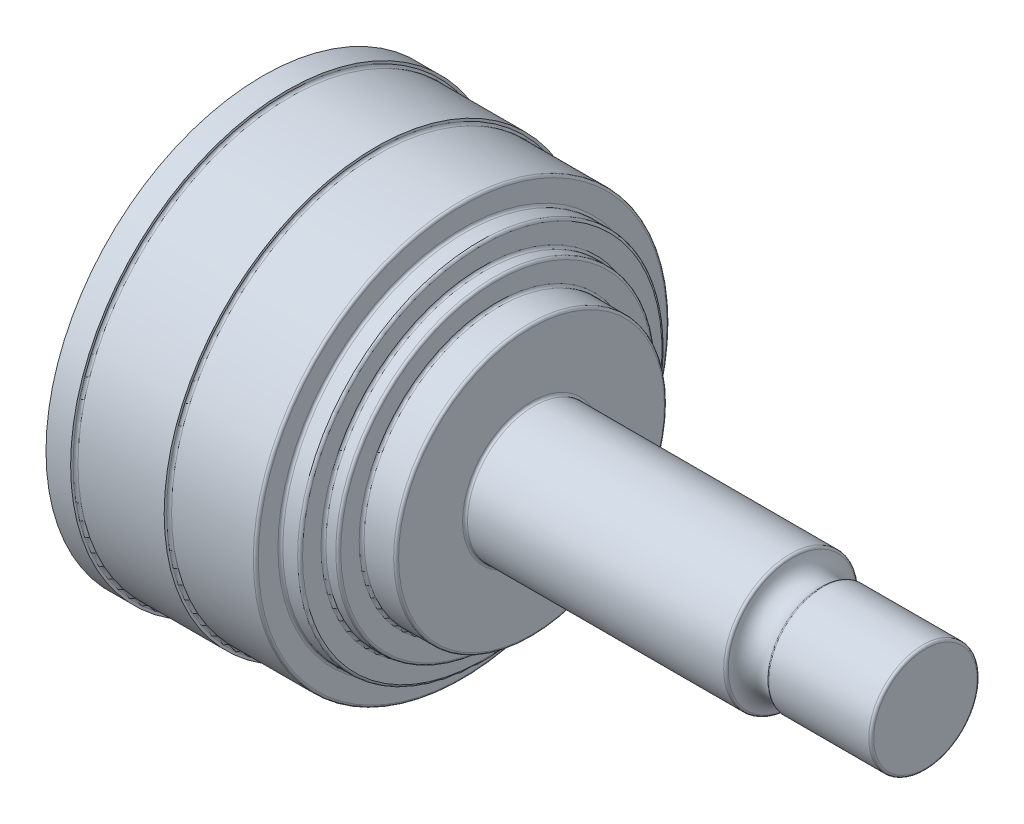
from build123d import *

# Parameters (mm, degrees)
FILLET1_R = 0.5


with BuildPart() as part:
    # Sketch1 → Revolve1 (revolve)
    with BuildSketch(Plane.XY):
        with BuildLine():
            Line((134.6, 0), (134.6, 11))
            Line((134.6, 11), (113.6, 11))
            ThreePointArc((113.6, 11), (109.766666667, 10.25), (107.6, 13.5))
            Line((107.6, 13.5), (54.6, 13.5))
            Line((54.6, 13.5), (54.6, 27.5))
            Line((54.6, 27.5), (47.6, 27.5))
            Line((47.6, 27.5), (47.6, 32.25))
            Line((47.6, 32.25), (44.6, 32.25))
            Line((44.6, 32.25), (44.6, 37))
            Line((44.6, 37), (40.6, 37))
            Line((40.6, 37), (40.6, 42))
            Line((40.6, 42), (23, 42))
            Line((23, 42), (23, 43))
            Line((23, 43), (5, 43))
            Line((5, 43), (5, 44))
            Line((5, 44), (0, 44))
            Line((0, 44), (0, 0))
            Line((0, 0), (134.6, 0))
        make_face()
    revolve(axis=Axis((-159.727345132, 0, 0), (1, 0, 0)))

    # Fillet1
    fillet1_edges = [part.edges().sort_by_distance(p)[0] for p in [
        (5, -43, 0),
        (23, -42, 0),
        (40.6, -42, 0),
        (40.6, -37, 0),
        (44.6, -37, 0),
        (44.6, -32.25, 0),
        (47.6, -32.25, 0),
        (47.6, -27.5, 0),
        (54.6, -27.5, 0),
        (54.6, -13.5, 0),
        (107.6, -13.5, 0),
        (113.6, -11, 0),
        (134.6, -11, 0),
    ]]
    fillet(fillet1_edges, radius=FILLET1_R)


solid = part.part
